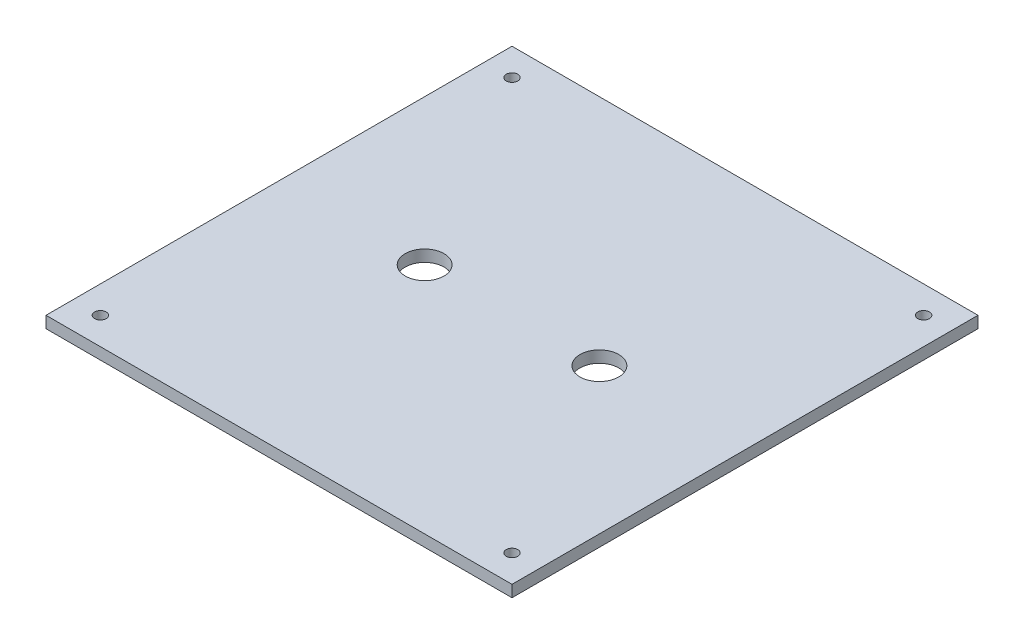
from build123d import *

# Parameters (mm, degrees)
SKETCH1_W           = 120
SKETCH1_H           = 120
BOSS_EXTRUDE1_DEPTH = 3
SKETCH4_R           = 5
CUT_EXTRUDE2_DEPTH  = 3
SKETCH7_R           = 1.5
CUT_EXTRUDE3_DEPTH  = 3


with BuildPart() as part:
    # Sketch1 → Boss-Extrude1 (new body)
    with BuildSketch(Plane(origin=(0, 0, 0), x_dir=(1, 0, 0), z_dir=(0, 1, 0))):
        Rectangle(SKETCH1_W, SKETCH1_H)
    extrude(amount=BOSS_EXTRUDE1_DEPTH)

    # Sketch4 → Cut-Extrude2 (cut)
    with BuildSketch(Plane(origin=(0, 0, 0), x_dir=(1, 0, 0), z_dir=(0, 1, 0))):
        with Locations((-22.5, 0)):
            Circle(SKETCH4_R)
        with Locations((22.5, 0)):
            Circle(SKETCH4_R)
    extrude(amount=CUT_EXTRUDE2_DEPTH, mode=Mode.SUBTRACT)

    # Sketch7 → Cut-Extrude3 (cut)
    with BuildSketch(Plane(origin=(0, 0, 0), x_dir=(1, 0, 0), z_dir=(0, 1, 0))):
        with Locations((-53, 53)):
            Circle(SKETCH7_R)
        with Locations((53, 53)):
            Circle(SKETCH7_R)
        with Locations((-53, -53)):
            Circle(SKETCH7_R)
        with Locations((53, -53)):
            Circle(SKETCH7_R)
    extrude(amount=CUT_EXTRUDE3_DEPTH, mode=Mode.SUBTRACT)


solid = part.part
